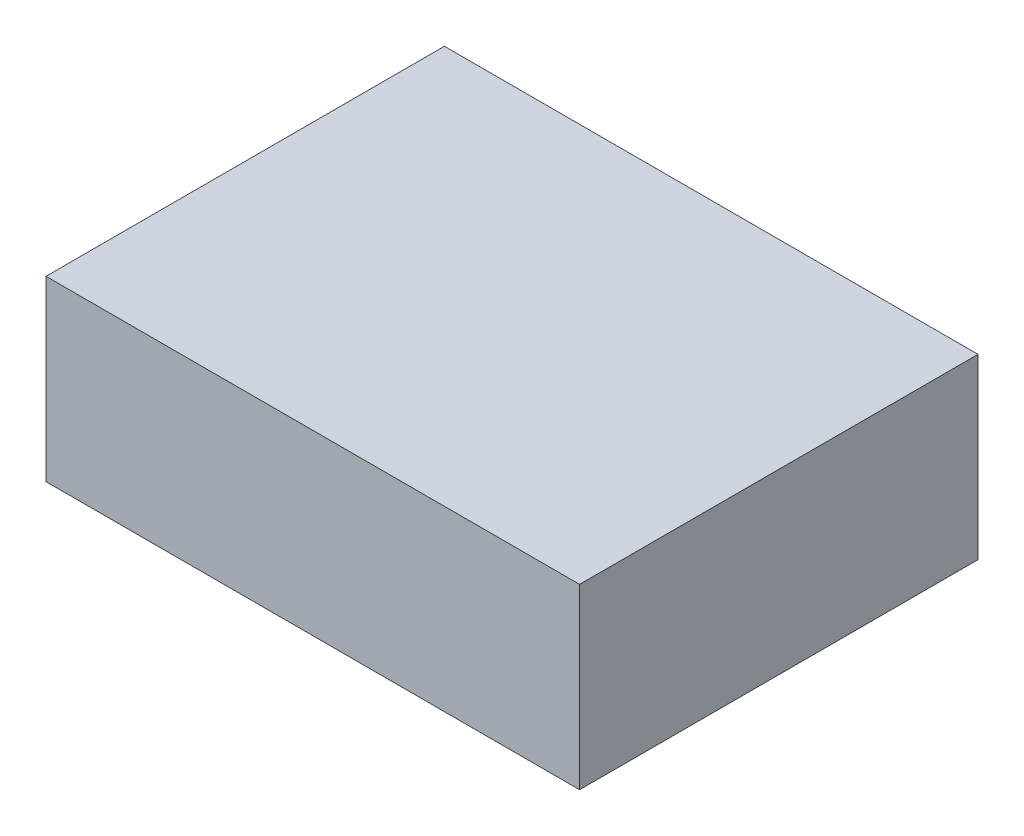
from build123d import *

# Parameters (mm, degrees)
SKETCH1_W           = 95.25
SKETCH1_H           = 71.12
BOSS_EXTRUDE1_DEPTH = 31.75


with BuildPart() as part:
    # Sketch1 → Boss-Extrude1 (new body)
    with BuildSketch(Plane(origin=(0, 0, 0), x_dir=(1, 0, 0), z_dir=(0, 1, 0))):
        with Locations((47.625, 35.56)):
            Rectangle(SKETCH1_W, SKETCH1_H)
    extrude(amount=BOSS_EXTRUDE1_DEPTH)


solid = part.part
